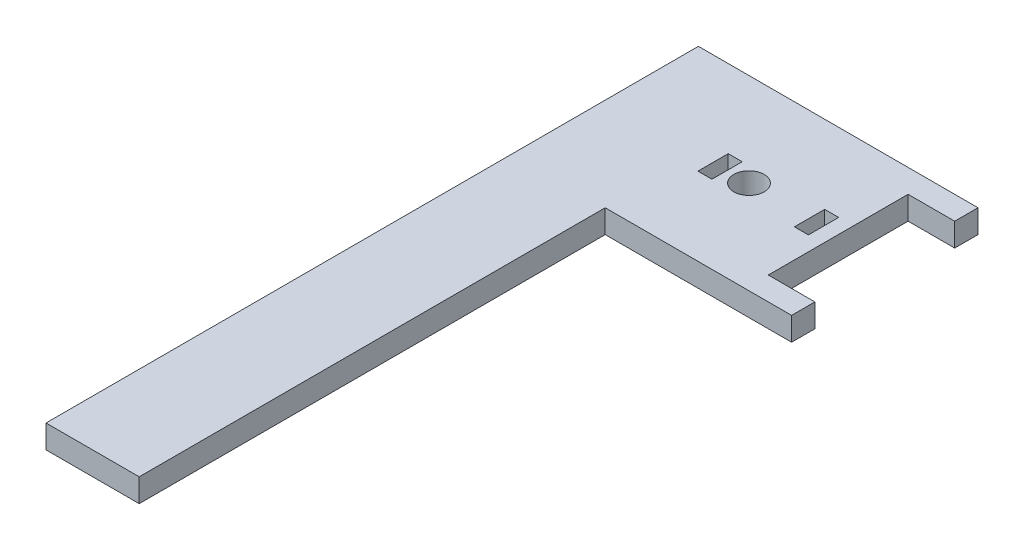
from build123d import *

# Parameters (mm, degrees)
SKETCH1_R               = 3.25
BOSS_EXTRUDE1_DEPTH     = 5
SKETCH3_W               = 20
SKETCH3_H               = 140
BOSS_EXTRUDE2_DEPTH     = 5
SKETCH4_W               = 3
SKETCH4_H               = 6.5
CUT_EXTRUDE1_DEPTH      = 1
CUT_EXTRUDE1_DEPTH_BACK = 6


with BuildPart() as part:
    # Sketch1 → Boss-Extrude1 (new body)
    with BuildSketch(Plane(origin=(0, 0, 0), x_dir=(1, 0, 0), z_dir=(0, 1, 0))):
        Polygon((-20, -15), (-30, -15), (-30, 15), (-20, 15), (-20, 20), (-60, 20), (-60, -20), (-20, -20), align=None)
        with Locations((-49.15, 0)):
            Circle(SKETCH1_R, mode=Mode.SUBTRACT)
    extrude(amount=BOSS_EXTRUDE1_DEPTH)

    # Sketch3 → Boss-Extrude2 (add)
    with BuildSketch(Plane(origin=(0, 0, 0), x_dir=(1, 0, 0), z_dir=(0, 1, 0))):
        with Locations((-70, -50)):
            Rectangle(SKETCH3_W, SKETCH3_H)
    extrude(amount=BOSS_EXTRUDE2_DEPTH)

    # Sketch4 → Cut-Extrude1 (cut, two sides)
    with BuildSketch(Plane(origin=(0, 5, 0), x_dir=(1, 0, 0), z_dir=(0, 1, 0))) as cut_extrude1_sk:
        with Locations((-34.65, 0)):
            Rectangle(SKETCH4_W, SKETCH4_H)
        with Locations((-55.35, 0)):
            Rectangle(SKETCH4_W, SKETCH4_H)
    extrude(amount=CUT_EXTRUDE1_DEPTH, mode=Mode.SUBTRACT)
    extrude(cut_extrude1_sk.sketch, amount=-CUT_EXTRUDE1_DEPTH_BACK, mode=Mode.SUBTRACT)


solid = part.part
